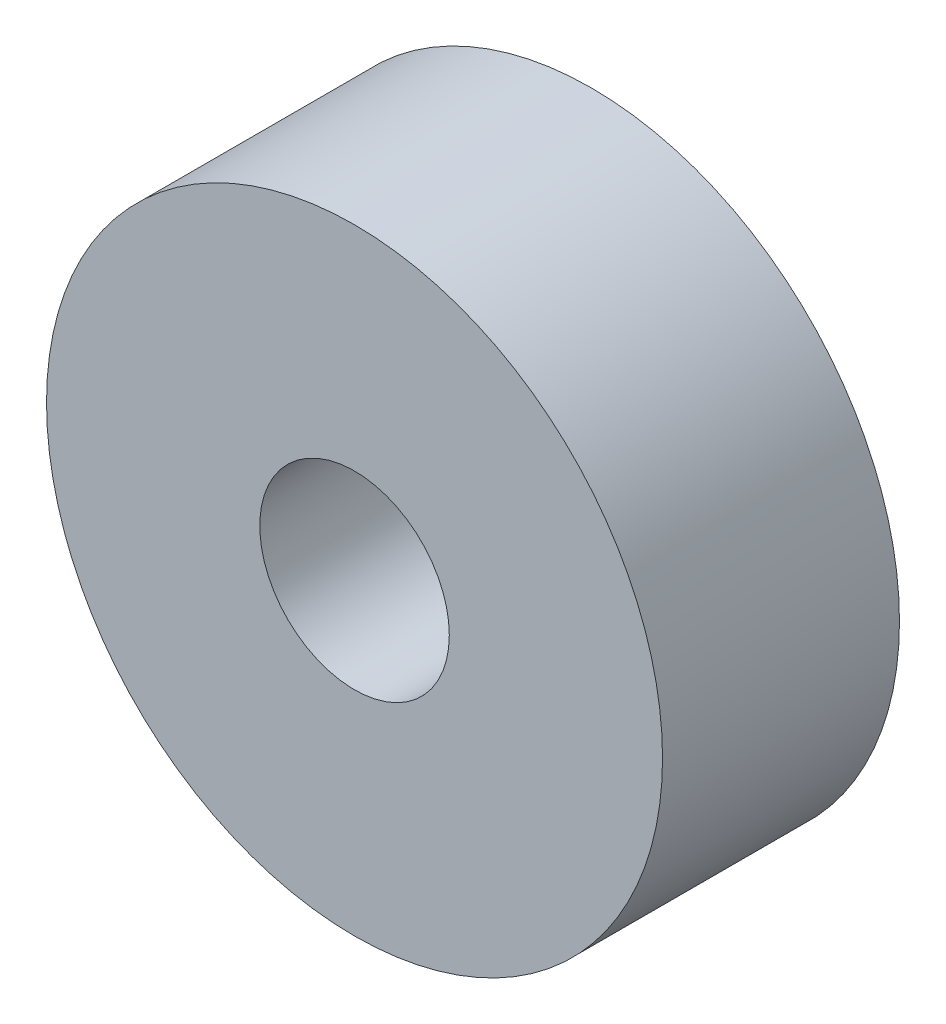
from build123d import *

# Parameters (mm, degrees)
SKETCH1_R           = 6.5
SKETCH1_R_2         = 2
BOSS_EXTRUDE1_DEPTH = 2.5


with BuildPart() as part:
    # Sketch1 → Boss-Extrude1 (new body, symmetric)
    with BuildSketch(Plane.XY):
        Circle(SKETCH1_R)
        Circle(SKETCH1_R_2, mode=Mode.SUBTRACT)
    extrude(amount=BOSS_EXTRUDE1_DEPTH, both=True)


solid = part.part
